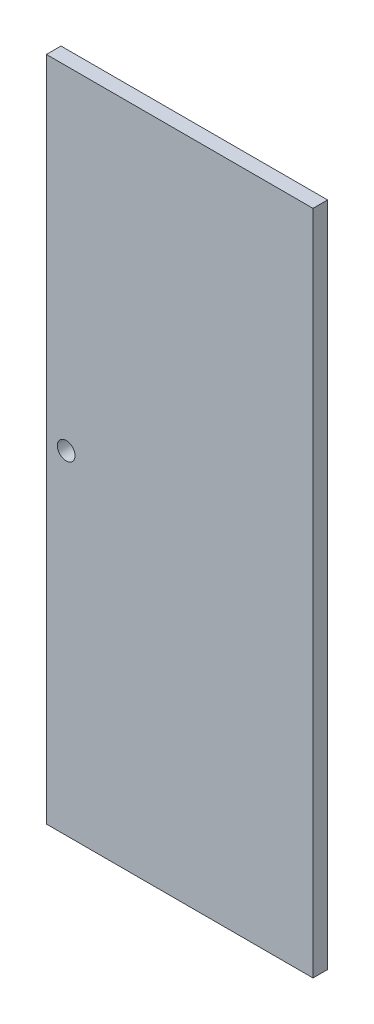
from build123d import *

# Parameters (mm, degrees)
SKETCH1_W           = 812.8
SKETCH1_H           = 2032
BOSS_EXTRUDE1_DEPTH = 44.45
SKETCH2_R           = 26.9875
CUT_EXTRUDE1_DEPTH  = 44.45


with BuildPart() as part:
    # Sketch1 → Boss-Extrude1 (new body)
    with BuildSketch(Plane.XY):
        with Locations((1166.971038615, 1018.392876165)):
            Rectangle(SKETCH1_W, SKETCH1_H)
    extrude(amount=BOSS_EXTRUDE1_DEPTH)

    # Sketch2 → Cut-Extrude1 (cut)
    with BuildSketch(Plane.XY.offset(44.45)):
        with Locations((820.896038615, 1018.392876165)):
            Circle(SKETCH2_R)
    extrude(amount=-CUT_EXTRUDE1_DEPTH, mode=Mode.SUBTRACT)


solid = part.part
